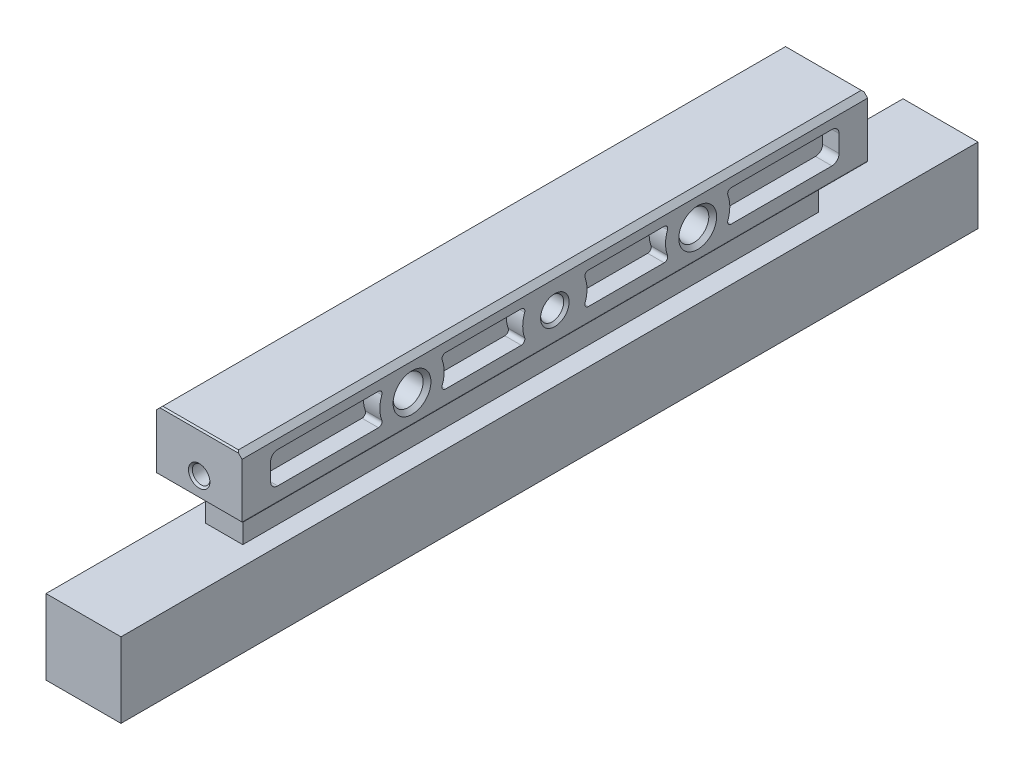
from build123d import *

# Parameters (mm, degrees)
BOSS_EXTRUDE1_DEPTH      = 60
BOSS_EXTRUDE1_DEPTH_BACK = 60
CUT_EXTRUDE1_DEPTH       = 12
CUT_EXTRUDE1_DEPTH_BACK  = 12
CUT_EXTRUDE2_DEPTH       = 2.3
CUT_EXTRUDE3_DEPTH       = 2.3
CUT_EXTRUDE4_DEPTH       = 2.3
CUT_EXTRUDE5_DEPTH       = 2.3
CUT_EXTRUDE6_START       = 2.3
CUT_EXTRUDE6_DEPTH       = 2.3
CUT_EXTRUDE7_START       = 2.3
CUT_EXTRUDE7_DEPTH       = 2.3
CUT_EXTRUDE8_START       = 2.3
CUT_EXTRUDE8_DEPTH       = 2.3
CUT_EXTRUDE9_START       = 2.3
CUT_EXTRUDE9_DEPTH       = 2.3


with BuildPart() as part:
    # Sketch1 → Boss-Extrude1 (new, two sides: drawn at the far end of the back side and taken through both)
    with BuildSketch(Plane.XY.offset(-BOSS_EXTRUDE1_DEPTH_BACK)):
        with BuildLine():
            Line((-5.8, 16.5), (-2.9, 16.5))
            ThreePointArc((-2.9, 16.5), (-2.687867966, 16.412132034), (-2.6, 16.2))
            Line((-2.6, 16.2), (-2.6, 10.5))
            Line((-2.6, 10.5), (-5.25, 10.5))
            Line((-5.25, 10.5), (-5.25, 0))
            Line((-5.25, 0), (5.25, 0))
            Line((5.25, 0), (5.25, 10.5))
            Line((5.25, 10.5), (2.6, 10.5))
            Line((2.6, 10.5), (2.6, 16.2))
            ThreePointArc((2.6, 16.2), (2.687867966, 16.412132034), (2.9, 16.5))
            Line((2.9, 16.5), (5.8, 16.5))
            ThreePointArc((5.8, 16.5), (5.941421356, 16.558578644), (6, 16.7))
            Line((6, 16.7), (6, 24.3))
            Line((6, 24.3), (5.3, 25))
            Line((5.3, 25), (-5.3, 25))
            Line((-5.3, 25), (-6, 24.3))
            Line((-6, 24.3), (-6, 16.7))
            ThreePointArc((-6, 16.7), (-5.941421356, 16.558578644), (-5.8, 16.5))
        make_face()
    extrude(amount=BOSS_EXTRUDE1_DEPTH + BOSS_EXTRUDE1_DEPTH_BACK)

    # Sketch2 → Cut-Extrude1 (cut, two sides: drawn at the far end of the back side and taken through both)
    with BuildSketch(Plane(origin=(0, 0, 0), x_dir=(0, 0, -1), z_dir=(1, 0, 0)).offset(-CUT_EXTRUDE1_DEPTH_BACK)):
        with BuildLine():
            Line((-65, 30), (-65, 10.5))
            Line((-65, 10.5), (-40.3, 10.5))
            Line((-40.3, 10.5), (-40.3, 16.2))
            ThreePointArc((-40.3, 16.2), (-40.387867966, 16.412132034), (-40.6, 16.5))
            Line((-40.6, 16.5), (-43.6, 16.5))
            Line((-43.6, 16.5), (-43.8, 16.7))
            Line((-43.8, 16.7), (-43.8, 24.8))
            Line((-43.8, 24.8), (-43.6, 25))
            Line((-43.6, 25), (43.6, 25))
            Line((43.6, 25), (43.8, 24.8))
            Line((43.8, 24.8), (43.8, 16.7))
            Line((43.8, 16.7), (43.6, 16.5))
            Line((43.6, 16.5), (40.6, 16.5))
            ThreePointArc((40.6, 16.5), (40.387867966, 16.412132034), (40.3, 16.2))
            Line((40.3, 16.2), (40.3, 10.5))
            Line((40.3, 10.5), (65, 10.5))
            Line((65, 10.5), (65, 30))
            Line((65, 30), (-65, 30))
        make_face()
    extrude(amount=CUT_EXTRUDE1_DEPTH + CUT_EXTRUDE1_DEPTH_BACK, mode=Mode.SUBTRACT)

    # Sketch3 → Cut-Revolve1 (revolve, cut)
    with BuildSketch(Plane.XY):
        Polygon((-6, 20.5), (-6, 22.5), (-5.621, 22.121), (5.621, 22.121), (6, 22.5), (6, 20.5), align=None)
    revolve(axis=Axis((6, 20.5, 0), (-1, 0, 0)), mode=Mode.SUBTRACT)

    # Sketch4 → Cut-Revolve2 (revolve, cut)
    with BuildSketch(Plane.XY.offset(20)):
        Polygon((-6, 20.5), (-6, 23.15), (-5.454778834, 22.6), (5.454778834, 22.6), (6, 23.15), (6, 20.5), align=None)
    revolve(axis=Axis((0, 20.5, 20), (-1, 0, 0)), mode=Mode.SUBTRACT)

    # Sketch5 → Cut-Revolve3 (revolve, cut)
    with BuildSketch(Plane.XY.offset(-20)):
        Polygon((-6, 20.5), (-6, 23.15), (-5.454778834, 22.6), (5.454778834, 22.6), (6, 23.15), (6, 20.5), align=None)
    revolve(axis=Axis((0, 20.5, -20), (-1, 0, 0)), mode=Mode.SUBTRACT)

    # Sketch6 → Cut-Revolve4 (revolve, cut)
    with BuildSketch(Plane(origin=(0, 0, 0), x_dir=(0, 0, -1), z_dir=(1, 0, 0))):
        Polygon((-43.8, 19.3), (-43.8, 20.8), (-43.5295, 20.5295), (-33.3, 20.5295), (-32.590147844, 19.3), align=None)
    revolve(axis=Axis((0, 19.3, 32.590147844), (0, 0, 1)), mode=Mode.SUBTRACT)

    # Sketch7 → Cut-Extrude2 (cut)
    with BuildSketch(Plane(origin=(6, 0, 0), x_dir=(0, 0, -1), z_dir=(1, 0, 0))):
        with BuildLine():
            Line((24.698499761, 18.58), (38.8, 18.58))
            ThreePointArc((38.8, 18.58), (39.507106781, 18.872893219), (39.8, 19.58))
            Line((39.8, 19.58), (39.8, 22))
            ThreePointArc((39.8, 22), (39.507106781, 22.707106781), (38.8, 23))
            Line((38.8, 23), (24.698499761, 23))
            ThreePointArc((24.698499761, 23), (24.288926812, 22.786792608), (24.228649785, 22.329))
            ThreePointArc((24.228649785, 22.329), (24.5, 20.79), (24.228649785, 19.251))
            ThreePointArc((24.228649785, 19.251), (24.288926812, 18.793207392), (24.698499761, 18.58))
        make_face()
    extrude(amount=-CUT_EXTRUDE2_DEPTH, mode=Mode.SUBTRACT)

    # Sketch8 → Cut-Extrude3 (cut)
    with BuildSketch(Plane(origin=(6, 0, 0), x_dir=(0, 0, -1), z_dir=(1, 0, 0))):
        with BuildLine():
            Line((-39.8, 22), (-39.8, 19.58))
            ThreePointArc((-39.8, 19.58), (-39.507106781, 18.872893219), (-38.8, 18.58))
            Line((-38.8, 18.58), (-24.698499761, 18.58))
            ThreePointArc((-24.698499761, 18.58), (-24.288926812, 18.793207392), (-24.228649785, 19.251))
            ThreePointArc((-24.228649785, 19.251), (-24.5, 20.79), (-24.228649785, 22.329))
            ThreePointArc((-24.228649785, 22.329), (-24.288926812, 22.786792608), (-24.698499761, 23))
            Line((-24.698499761, 23), (-38.8, 23))
            ThreePointArc((-38.8, 23), (-39.507106781, 22.707106781), (-39.8, 22))
        make_face()
    extrude(amount=-CUT_EXTRUDE3_DEPTH, mode=Mode.SUBTRACT)

    # Sketch9 → Cut-Extrude4 (cut)
    with BuildSketch(Plane(origin=(6, 0, 0), x_dir=(0, 0, -1), z_dir=(1, 0, 0))):
        with BuildLine():
            Line((4.698499761, 18.58), (15.301500239, 18.58))
            ThreePointArc((15.301500239, 18.58), (15.711073188, 18.793207392), (15.771350215, 19.251))
            ThreePointArc((15.771350215, 19.251), (15.5, 20.79), (15.771350215, 22.329))
            ThreePointArc((15.771350215, 22.329), (15.711073188, 22.786792608), (15.301500239, 23))
            Line((15.301500239, 23), (4.698499761, 23))
            ThreePointArc((4.698499761, 23), (4.288926812, 22.786792608), (4.228649785, 22.329))
            ThreePointArc((4.228649785, 22.329), (4.5, 20.79), (4.228649785, 19.251))
            ThreePointArc((4.228649785, 19.251), (4.288926812, 18.793207392), (4.698499761, 18.58))
        make_face()
    extrude(amount=-CUT_EXTRUDE4_DEPTH, mode=Mode.SUBTRACT)

    # Sketch10 → Cut-Extrude5 (cut)
    with BuildSketch(Plane(origin=(6, 0, 0), x_dir=(0, 0, -1), z_dir=(1, 0, 0))):
        with BuildLine():
            Line((-15.301500239, 18.58), (-4.698499761, 18.58))
            ThreePointArc((-4.698499761, 18.58), (-4.288926812, 18.793207392), (-4.228649785, 19.251))
            ThreePointArc((-4.228649785, 19.251), (-4.5, 20.79), (-4.228649785, 22.329))
            ThreePointArc((-4.228649785, 22.329), (-4.288926812, 22.786792608), (-4.698499761, 23))
            Line((-4.698499761, 23), (-15.301500239, 23))
            ThreePointArc((-15.301500239, 23), (-15.711073188, 22.786792608), (-15.771350215, 22.329))
            ThreePointArc((-15.771350215, 22.329), (-15.5, 20.79), (-15.771350215, 19.251))
            ThreePointArc((-15.771350215, 19.251), (-15.711073188, 18.793207392), (-15.301500239, 18.58))
        make_face()
    extrude(amount=-CUT_EXTRUDE5_DEPTH, mode=Mode.SUBTRACT)

    # Sketch11 → Cut-Extrude6 (cut)
    with BuildSketch(Plane(origin=(-6, 0, 0), x_dir=(0, 0, -1), z_dir=(1, 0, 0)).offset(CUT_EXTRUDE6_START)):
        with BuildLine():
            Line((24.698499761, 18.58), (38.8, 18.58))
            ThreePointArc((38.8, 18.58), (39.507106781, 18.872893219), (39.8, 19.58))
            Line((39.8, 19.58), (39.8, 22))
            ThreePointArc((39.8, 22), (39.507106781, 22.707106781), (38.8, 23))
            Line((38.8, 23), (24.698499761, 23))
            ThreePointArc((24.698499761, 23), (24.288926812, 22.786792608), (24.228649785, 22.329))
            ThreePointArc((24.228649785, 22.329), (24.5, 20.79), (24.228649785, 19.251))
            ThreePointArc((24.228649785, 19.251), (24.288926812, 18.793207392), (24.698499761, 18.58))
        make_face()
    extrude(amount=-CUT_EXTRUDE6_DEPTH, mode=Mode.SUBTRACT)

    # Sketch12 → Cut-Extrude7 (cut)
    with BuildSketch(Plane(origin=(-6, 0, 0), x_dir=(0, 0, -1), z_dir=(1, 0, 0)).offset(CUT_EXTRUDE7_START)):
        with BuildLine():
            Line((-39.8, 22), (-39.8, 19.58))
            ThreePointArc((-39.8, 19.58), (-39.507106781, 18.872893219), (-38.8, 18.58))
            Line((-38.8, 18.58), (-24.698499761, 18.58))
            ThreePointArc((-24.698499761, 18.58), (-24.288926812, 18.793207392), (-24.228649785, 19.251))
            ThreePointArc((-24.228649785, 19.251), (-24.5, 20.79), (-24.228649785, 22.329))
            ThreePointArc((-24.228649785, 22.329), (-24.288926812, 22.786792608), (-24.698499761, 23))
            Line((-24.698499761, 23), (-38.8, 23))
            ThreePointArc((-38.8, 23), (-39.507106781, 22.707106781), (-39.8, 22))
        make_face()
    extrude(amount=-CUT_EXTRUDE7_DEPTH, mode=Mode.SUBTRACT)

    # Sketch13 → Cut-Extrude8 (cut)
    with BuildSketch(Plane(origin=(-6, 0, 0), x_dir=(0, 0, -1), z_dir=(1, 0, 0)).offset(CUT_EXTRUDE8_START)):
        with BuildLine():
            Line((4.698499761, 18.58), (15.301500239, 18.58))
            ThreePointArc((15.301500239, 18.58), (15.711073188, 18.793207392), (15.771350215, 19.251))
            ThreePointArc((15.771350215, 19.251), (15.5, 20.79), (15.771350215, 22.329))
            ThreePointArc((15.771350215, 22.329), (15.711073188, 22.786792608), (15.301500239, 23))
            Line((15.301500239, 23), (4.698499761, 23))
            ThreePointArc((4.698499761, 23), (4.288926812, 22.786792608), (4.228649785, 22.329))
            ThreePointArc((4.228649785, 22.329), (4.5, 20.79), (4.228649785, 19.251))
            ThreePointArc((4.228649785, 19.251), (4.288926812, 18.793207392), (4.698499761, 18.58))
        make_face()
    extrude(amount=-CUT_EXTRUDE8_DEPTH, mode=Mode.SUBTRACT)

    # Sketch14 → Cut-Extrude9 (cut)
    with BuildSketch(Plane(origin=(-6, 0, 0), x_dir=(0, 0, -1), z_dir=(1, 0, 0)).offset(CUT_EXTRUDE9_START)):
        with BuildLine():
            Line((-15.301500239, 18.58), (-4.698499761, 18.58))
            ThreePointArc((-4.698499761, 18.58), (-4.288926812, 18.793207392), (-4.228649785, 19.251))
            ThreePointArc((-4.228649785, 19.251), (-4.5, 20.79), (-4.228649785, 22.329))
            ThreePointArc((-4.228649785, 22.329), (-4.288926812, 22.786792608), (-4.698499761, 23))
            Line((-4.698499761, 23), (-15.301500239, 23))
            ThreePointArc((-15.301500239, 23), (-15.711073188, 22.786792608), (-15.771350215, 22.329))
            ThreePointArc((-15.771350215, 22.329), (-15.5, 20.79), (-15.771350215, 19.251))
            ThreePointArc((-15.771350215, 19.251), (-15.711073188, 18.793207392), (-15.301500239, 18.58))
        make_face()
    extrude(amount=-CUT_EXTRUDE9_DEPTH, mode=Mode.SUBTRACT)


solid = part.part
